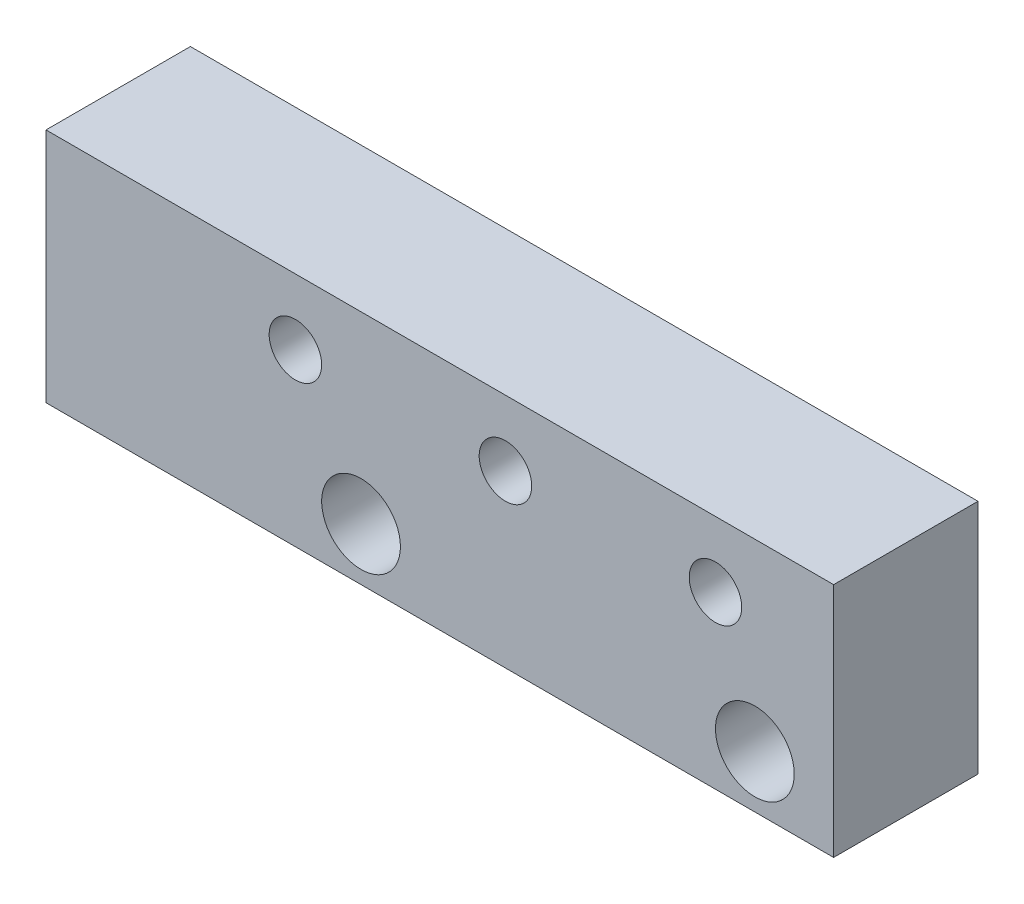
from build123d import *

# Parameters (mm, degrees)
ESQUISSE1_W             = 30
ESQUISSE1_H             = 9
BOSS_EXTRU_1_DEPTH      = 5.5
ESQUISSE3_R             = 1
ENL_V_MAT_EXTRU_2_DEPTH = 6.5
ESQUISSE4_R             = 1.5
ENL_V_MAT_EXTRU_3_DEPTH = 10


with BuildPart() as part:
    # Esquisse1 → Boss.-Extru.1 (new body)
    with BuildSketch(Plane.XY):
        with Locations((-4.19131449, -1.696581197)):
            Rectangle(ESQUISSE1_W, ESQUISSE1_H)
    extrude(amount=BOSS_EXTRU_1_DEPTH)

    # Esquisse3 → Enlèv. mat.-Extru.2 (cut, through all)
    with BuildSketch(Plane.XY.offset(5.5)):
        with Locations((6.30868551, 0.303418803)):
            Circle(ESQUISSE3_R)
        with Locations((-1.69131449, 0.303418803)):
            Circle(ESQUISSE3_R)
        with Locations((-9.69131449, 0.303418803)):
            Circle(ESQUISSE3_R)
    extrude(amount=-ENL_V_MAT_EXTRU_2_DEPTH, mode=Mode.SUBTRACT)

    # Esquisse4 → Enlèv. mat.-Extru.3 (cut)
    with BuildSketch(Plane.XY.offset(5.5)):
        with Locations((-7.19131449, -4.196581197)):
            Circle(ESQUISSE4_R)
        with Locations((7.80868551, -4.196581197)):
            Circle(ESQUISSE4_R)
    extrude(amount=-ENL_V_MAT_EXTRU_3_DEPTH, mode=Mode.SUBTRACT)


solid = part.part
